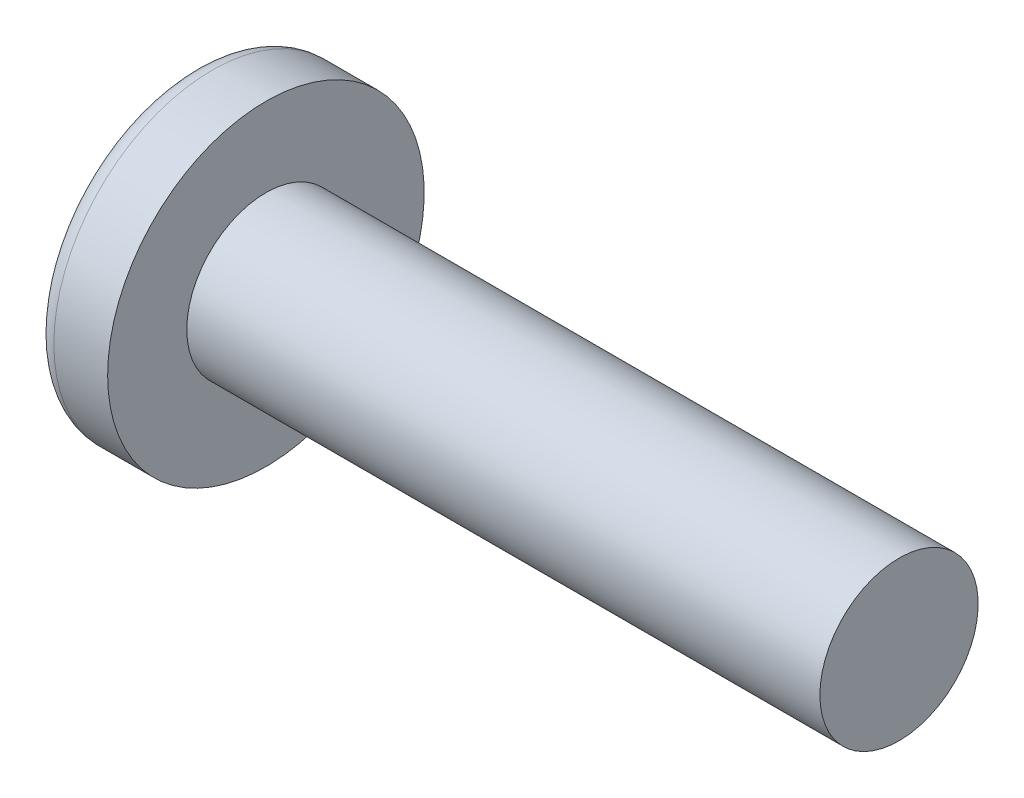
from build123d import *

# Parameters (mm, degrees)
SKETCH3_W         = 1.84
SKETCH3_H         = 10.18
SKETCH4_W         = 0.92
SKETCH4_H         = 0.92
CIRPATTERN1_COUNT = 2
CIRPATTERN1_ANGLE = 90


with BuildPart() as part:
    # BodySke → Base-Revolve (revolve)
    with BuildSketch(Plane.XY):
        with BuildLine():
            Line((7.5, 5), (7.5, 10))
            Line((7.5, 10), (4.100420175, 10))
            ThreePointArc((4.100420175, 10), (3.560149973, 9.871498067), (3.135589379, 9.513513514))
            ThreePointArc((3.135589379, 9.513513514), (0.804103022, 5.008464339), (0, 0))
            Line((0, 0), (47.5, 0))
            Line((47.5, 0), (47.5, 5))
            Line((47.5, 5), (7.5, 5))
        make_face()
    revolve(axis=Axis((-25.4, 0, 0), (1, 0, 0)))

    # Sketch3 → Cut-Loft1 section 0
    with BuildSketch(Plane(origin=(0, 0, 0), x_dir=(0, 0, -1), z_dir=(1, 0, 0))):
        Rectangle(SKETCH3_W, SKETCH3_H)
    # Sketch4 → Cut-Loft1 section 1
    with BuildSketch(Plane(origin=(6.09, 0, 0), x_dir=(0, 0, -1), z_dir=(1, 0, 0))):
        Rectangle(SKETCH4_W, SKETCH4_H)
    cut_loft1 = loft(mode=Mode.SUBTRACT)

    # CirPattern1: Cut-Loft1 ×2 about axis
    cirpattern1_axis = Axis((0, 0, 0), (1, 0, 0))
    for i in range(1, CIRPATTERN1_COUNT):
        add(cut_loft1.rotate(cirpattern1_axis, i * CIRPATTERN1_ANGLE / (CIRPATTERN1_COUNT - 1)), mode=Mode.SUBTRACT)


solid = part.part
